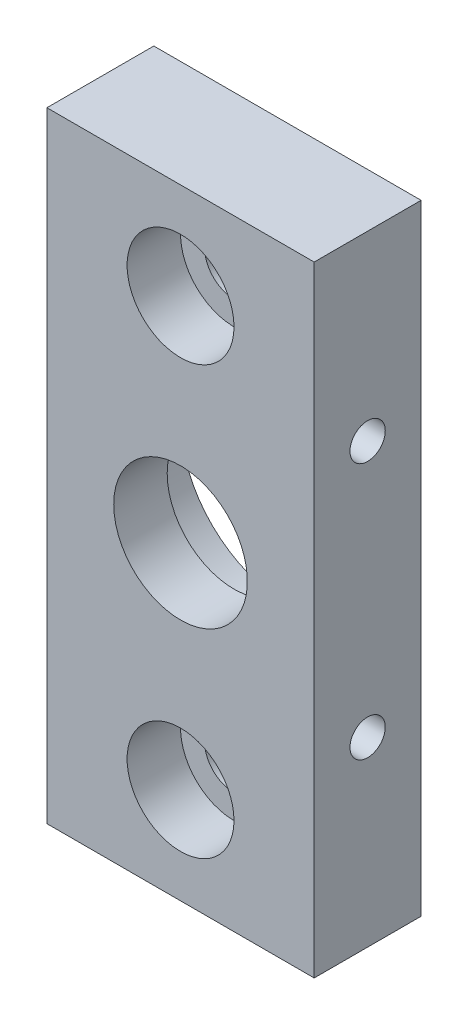
from build123d import *

# Parameters (mm, degrees)
ESQUISSE1_W                                        = 25
ESQUISSE1_H                                        = 58
BOSS_EXTRU_1_DEPTH                                 = 10
ESQUISSE3_R                                        = 10
ENL_V_MAT_EXTRU_2_DEPTH                            = 5
ESQUISSE4_R                                        = 6.25
ENL_V_MAT_EXTRU_3_DEPTH                            = 6
CHAMBRAGE_POUR_VIS_T_TE_HEXAGONALE_M51_D           = 5.5
CHAMBRAGE_POUR_VIS_T_TE_HEXAGONALE_M51_CBORE_D     = 10
CHAMBRAGE_POUR_VIS_T_TE_HEXAGONALE_M51_CBORE_DEPTH = 5
CHAMBRAGE_POUR_VIS_T_TE_HEXAGONALE_M53_D           = 5.5
CHAMBRAGE_POUR_VIS_T_TE_HEXAGONALE_M53_CBORE_D     = 10
CHAMBRAGE_POUR_VIS_T_TE_HEXAGONALE_M53_CBORE_DEPTH = 5
TROU_TARAUD_M43_D                                  = 3.3
TROU_TARAUD_M42_D                                  = 3.3


with BuildPart() as part:
    # Esquisse1 → Boss.-Extru.1 (new body)
    with BuildSketch(Plane.XY):
        Rectangle(ESQUISSE1_W, ESQUISSE1_H)
    extrude(amount=BOSS_EXTRU_1_DEPTH)

    # Esquisse3 → Enlèv. mat.-Extru.2 (cut)
    with BuildSketch(Plane(origin=(0, 0, 0), x_dir=(-1, 0, 0), z_dir=(0, 0, -1))):
        Circle(ESQUISSE3_R)
    extrude(amount=-ENL_V_MAT_EXTRU_2_DEPTH, mode=Mode.SUBTRACT)

    # Esquisse4 → Enlèv. mat.-Extru.3 (cut, through all)
    with BuildSketch(Plane(origin=(0, 0, 5), x_dir=(-1, 0, 0), z_dir=(0, 0, -1))):
        Circle(ESQUISSE4_R)
    extrude(amount=-ENL_V_MAT_EXTRU_3_DEPTH, mode=Mode.SUBTRACT)

    # Chambrage pour vis à tête hexagonale M51 (through all)
    with Locations(Plane.XY.offset(10)):
        with Locations((0, -20)):
            CounterBoreHole(CHAMBRAGE_POUR_VIS_T_TE_HEXAGONALE_M51_D / 2, CHAMBRAGE_POUR_VIS_T_TE_HEXAGONALE_M51_CBORE_D / 2, CHAMBRAGE_POUR_VIS_T_TE_HEXAGONALE_M51_CBORE_DEPTH)

    # Chambrage pour vis à tête hexagonale M53 (through all)
    with Locations(Plane.XY.offset(10)):
        with Locations((0, 20)):
            CounterBoreHole(CHAMBRAGE_POUR_VIS_T_TE_HEXAGONALE_M53_D / 2, CHAMBRAGE_POUR_VIS_T_TE_HEXAGONALE_M53_CBORE_D / 2, CHAMBRAGE_POUR_VIS_T_TE_HEXAGONALE_M53_CBORE_DEPTH)

    # Trou taraudé M43 (through all)
    with Locations(Plane(origin=(12.5, 0, 0), x_dir=(0, 0, -1), z_dir=(1, 0, 0))):
        with Locations((-5, 12)):
            Hole(TROU_TARAUD_M43_D / 2)

    # Trou taraudé M42 (through all)
    with Locations(Plane.ZY.offset(12.5)):
        with Locations((5, -12)):
            Hole(TROU_TARAUD_M42_D / 2)


solid = part.part
